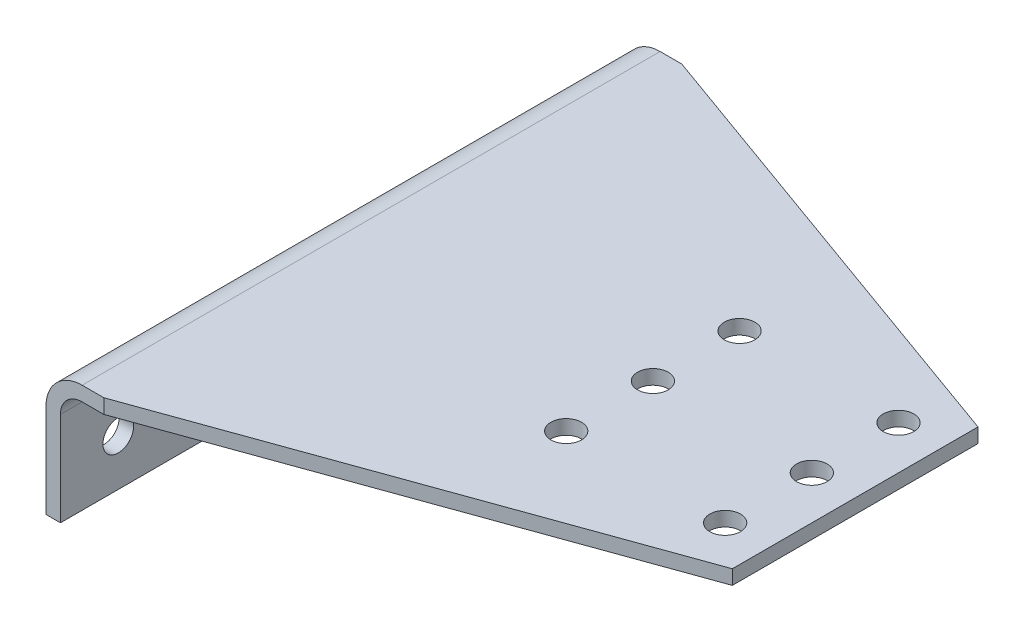
from build123d import *

# Parameters (mm, degrees)
EXTRUDE1_DEPTH         = 127
SKETCH2_R              = 6.731
CUT_CHAMFER_DEPTH      = 508
CUT_CHAMFER_DEPTH_BACK = 58.15
SKETCH3_R              = 6.731
CUT_HOLES_DEPTH        = 229.6


with BuildPart() as part:
    # Sketch1 → Extrude1 (new body, symmetric)
    with BuildSketch(Plane.XY):
        with BuildLine():
            Line((228.6, 0), (15.875, 0))
            ThreePointArc((15.875, 0), (4.649679849, -4.649679849), (0, -15.875))
            Line((0, -15.875), (0, -57.15))
            Line((0, -57.15), (6.35, -57.15))
            Line((6.35, -57.15), (6.35, -15.875))
            ThreePointArc((6.35, -15.875), (9.139807909, -9.139807909), (15.875, -6.35))
            Line((15.875, -6.35), (228.6, -6.35))
            Line((228.6, -6.35), (228.6, 0))
        make_face()
    extrude(amount=EXTRUDE1_DEPTH, both=True)

    # Sketch2 → Cut-Chamfer (cut, two sides)
    with BuildSketch(Plane(origin=(0, 0, 0), x_dir=(1, 0, 0), z_dir=(0, 1, 0))) as cut_chamfer_sk:
        with Locations((209.55, 38.1)):
            Circle(SKETCH2_R)
        with Locations((139.7, 38.1)):
            Circle(SKETCH2_R)
        with Locations((209.55, 0)):
            Circle(SKETCH2_R)
        with Locations((139.7, 0)):
            Circle(SKETCH2_R)
        with Locations((139.7, -38.1)):
            Circle(SKETCH2_R)
        with Locations((209.55, -38.1)):
            Circle(SKETCH2_R)
        Polygon((25.4, 127), (228.6, 53.975), (228.6, 127), align=None)
        Polygon((228.6, -53.975), (228.6, -127), (25.4, -127), align=None)
    extrude(amount=CUT_CHAMFER_DEPTH, mode=Mode.SUBTRACT)
    extrude(cut_chamfer_sk.sketch, amount=-CUT_CHAMFER_DEPTH_BACK, mode=Mode.SUBTRACT)

    # Sketch3 → Cut-Holes (cut, through all)
    with BuildSketch(Plane(origin=(0, 0, 0), x_dir=(0, 0, -1), z_dir=(1, 0, 0))):
        with Locations((0, -36.5125)):
            Circle(SKETCH3_R)
        with Locations((101.6, -36.5125)):
            Circle(SKETCH3_R)
        with Locations((0, -150.8125)):
            Circle(SKETCH3_R)
        with Locations((101.6, -150.8125)):
            Circle(SKETCH3_R)
        with Locations((-101.6, -36.5125)):
            Circle(SKETCH3_R)
        with Locations((-101.6, -150.8125)):
            Circle(SKETCH3_R)
        with Locations((-50.8, -36.5125)):
            Circle(SKETCH3_R)
        with Locations((50.8, -36.5125)):
            Circle(SKETCH3_R)
        with Locations((50.8, -150.8125)):
            Circle(SKETCH3_R)
        with Locations((-50.8, -150.8125)):
            Circle(SKETCH3_R)
    extrude(amount=CUT_HOLES_DEPTH, mode=Mode.SUBTRACT)


solid = part.part
